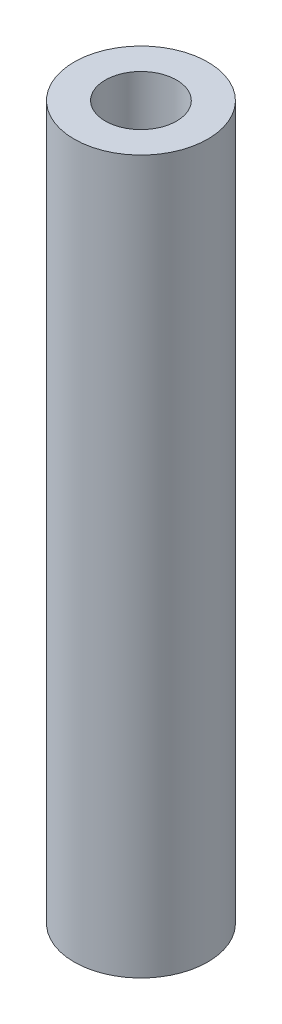
from build123d import *

# Parameters (mm, degrees)
SKETCH2_R           = 9.525
BOSS_EXTRUDE1_DEPTH = 101.6
SKETCH3_R           = 5.08
CUT_EXTRUDE1_DEPTH  = 102.6


with BuildPart() as part:
    # Sketch2 → Boss-Extrude1 (new body)
    with BuildSketch(Plane(origin=(0, 0, 0), x_dir=(1, 0, 0), z_dir=(0, 1, 0))):
        Circle(SKETCH2_R)
    extrude(amount=BOSS_EXTRUDE1_DEPTH)

    # Sketch3 → Cut-Extrude1 (cut, through all)
    with BuildSketch(Plane(origin=(0, 101.6, 0), x_dir=(1, 0, 0), z_dir=(0, 1, 0))):
        Circle(SKETCH3_R)
    extrude(amount=-CUT_EXTRUDE1_DEPTH, mode=Mode.SUBTRACT)


solid = part.part
